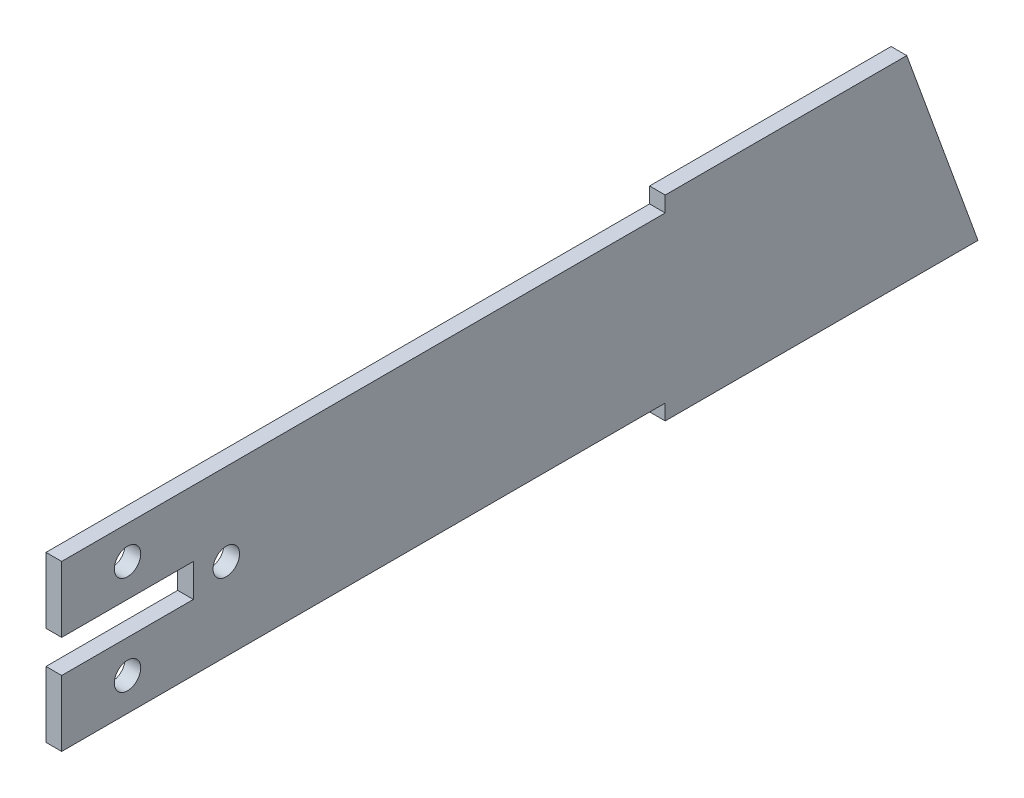
from build123d import *

# Parameters (mm, degrees)
SKETCH2_2_R         = 2.0193
BOSS_EXTRUDE2_DEPTH = 3.0226
SKETCH6_R           = 2.5527
CUT_EXTRUDE4_DEPTH  = 181.14196624


with BuildPart() as part:
    # Sketch2_2 → Boss-Extrude2 (new body)
    with BuildSketch(Plane(origin=(0, 0, 0), x_dir=(0, 0, -1), z_dir=(1, 0, 0))):
        Polygon((0, 0), (0, 12.7), (25.4, 12.7), (25.4, 19.05), (0, 19.05), (0, 31.75), (38.1, 31.75), (116.4082, 31.75), (116.4082, 34.7472), (162.99536189, 34.7472), (176.7332, -2.9972), (116.4082, -2.9972), (116.4082, 0), (38.1, 0), align=None)
        with Locations((12.7, 25.4)):
            Circle(SKETCH2_2_R, mode=Mode.SUBTRACT)
        with Locations((12.7, 6.35)):
            Circle(SKETCH2_2_R, mode=Mode.SUBTRACT)
        with Locations((31.75, 15.875)):
            Circle(SKETCH2_2_R, mode=Mode.SUBTRACT)
    extrude(amount=BOSS_EXTRUDE2_DEPTH)

    # Sketch6 → Cut-Extrude4 (cut, through all)
    with BuildSketch(Plane(origin=(3.0226, 0, 0), x_dir=(0, 0, -1), z_dir=(1, 0, 0))):
        with Locations((12.7, 25.4)):
            Circle(SKETCH6_R)
        with Locations((31.75, 15.875)):
            Circle(SKETCH6_R)
        with Locations((12.7, 6.35)):
            Circle(SKETCH6_R)
    extrude(amount=-CUT_EXTRUDE4_DEPTH, mode=Mode.SUBTRACT)


solid = part.part
